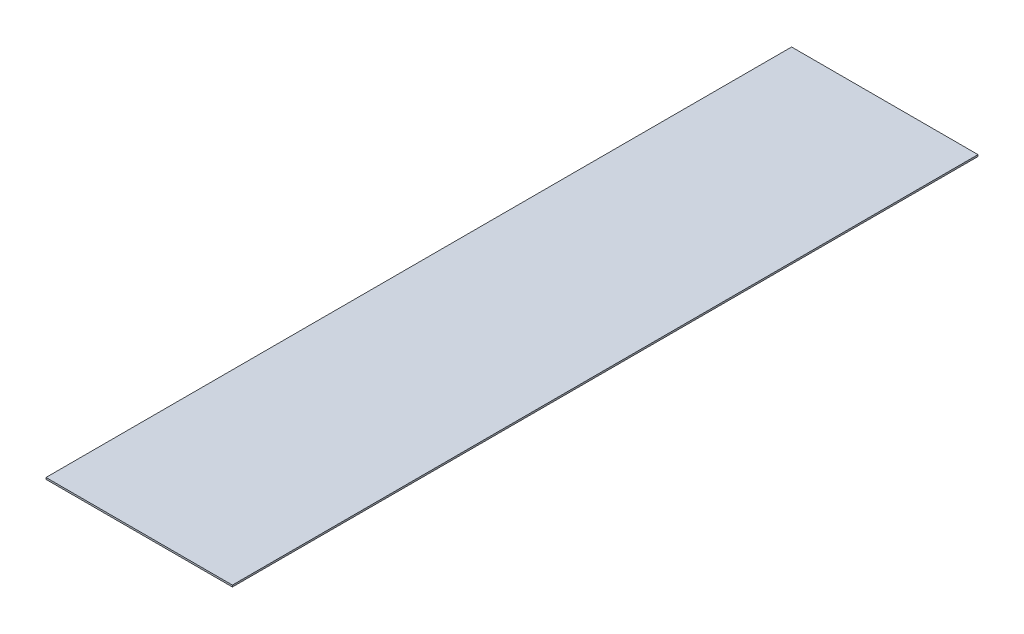
from build123d import *

# Parameters (mm, degrees)
SKETCH1_W           = 609.6
SKETCH1_H           = 2438.4
BOSS_EXTRUDE1_DEPTH = 5.55625


with BuildPart() as part:
    # Sketch1 → Boss-Extrude1 (new body)
    with BuildSketch(Plane(origin=(0, 0, 0), x_dir=(1, 0, 0), z_dir=(0, 1, 0))):
        Rectangle(SKETCH1_W, SKETCH1_H)
    extrude(amount=BOSS_EXTRUDE1_DEPTH)


solid = part.part
